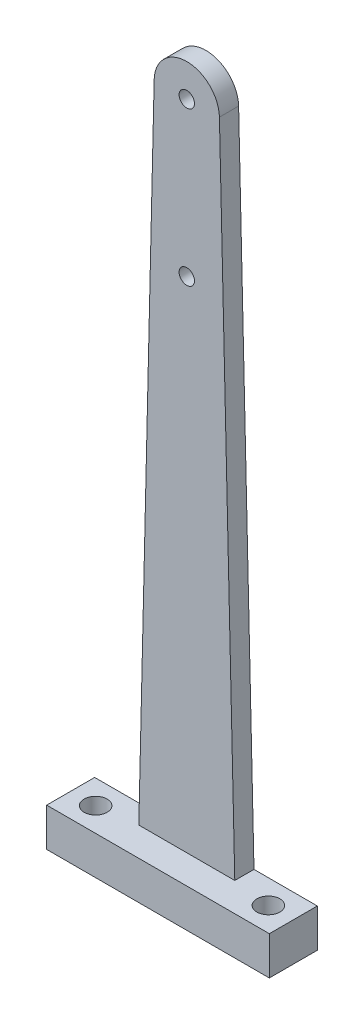
from build123d import *

# Parameters (mm, degrees)
SKETCH1_R           = 2
BOSS_EXTRUDE1_DEPTH = 5
SKETCH2_W           = 58
SKETCH2_H           = 10
BOSS_EXTRUDE2_DEPTH = 10
SKETCH3_R           = 3
CUT_EXTRUDE1_DEPTH  = 11


with BuildPart() as part:
    # Sketch1 → Boss-Extrude1 (new body)
    with BuildSketch(Plane.XY):
        with BuildLine():
            Line((-75.497650797, -127.154118822), (-79.5, -297.353946086))
            Line((-79.5, -297.353946086), (-96, -297.353946086))
            Line((-96, -297.353946086), (-96, -307.353946086))
            Line((-96, -307.353946086), (-38, -307.353946086))
            Line((-38, -307.353946086), (-38, -297.353946086))
            Line((-38, -297.353946086), (-54.5, -297.353946086))
            Line((-54.5, -297.353946086), (-58.502349203, -127.154118822))
            ThreePointArc((-58.502349203, -127.154118822), (-67, -118.853946086), (-75.497650797, -127.154118822))
        make_face()
        with Locations((-67, -167.353946086)):
            Circle(SKETCH1_R, mode=Mode.SUBTRACT)
        with Locations((-67, -127.353946086)):
            Circle(SKETCH1_R, mode=Mode.SUBTRACT)
    extrude(amount=BOSS_EXTRUDE1_DEPTH)

    # Sketch2 → Boss-Extrude2 (add)
    with BuildSketch(Plane.XY.offset(2.5)):
        with Locations((-67, -302.353946086)):
            Rectangle(SKETCH2_W, SKETCH2_H)
    extrude(amount=BOSS_EXTRUDE2_DEPTH)

    # Sketch3 → Cut-Extrude1 (cut, through all)
    with BuildSketch(Plane(origin=(0, -297.353946086, 0), x_dir=(1, 0, 0), z_dir=(0, 1, 0))):
        with Locations((-89.5, -6.25)):
            Circle(SKETCH3_R)
        with Locations((-44.5, -6.25)):
            Circle(SKETCH3_R)
    extrude(amount=-CUT_EXTRUDE1_DEPTH, mode=Mode.SUBTRACT)


solid = part.part
